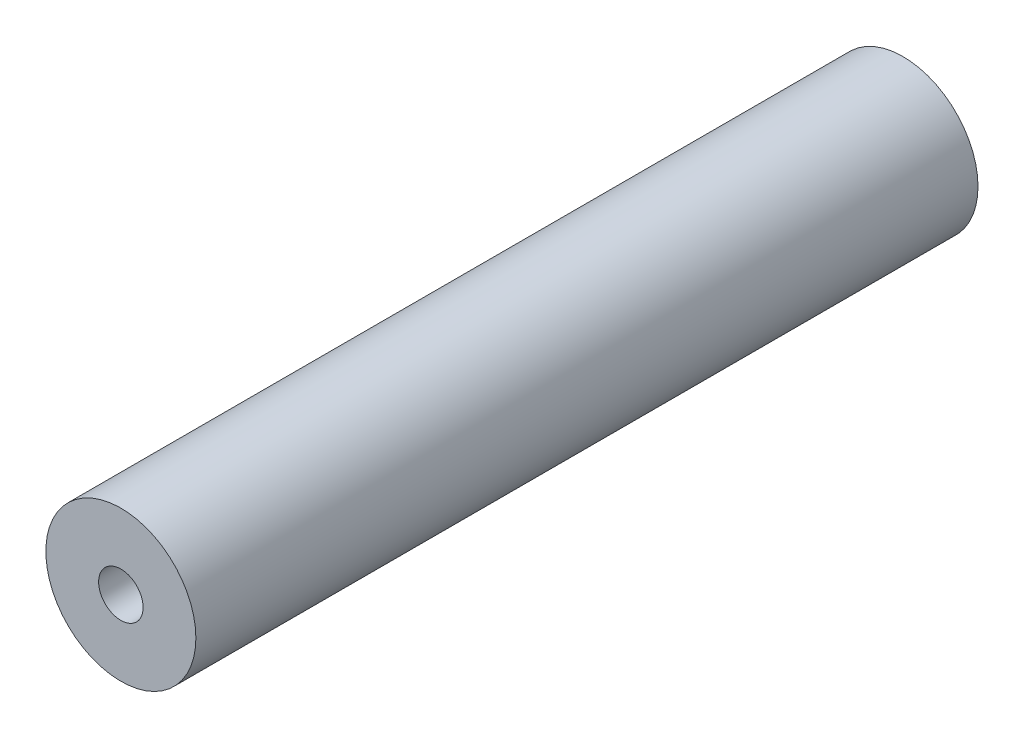
from build123d import *

# Parameters (mm, degrees)
SKETCH1_R                  = 6.4
BOSS_EXTRUDE1_DEPTH        = 66.73
F_10_24_TAPPED_HOLE1_D     = 3.7973
F_10_24_TAPPED_HOLE1_DEPTH = 12.83
F_10_24_TAPPED_HOLE1_TIP   = 1.140824014
F_10_24_TAPPED_HOLE2_D     = 3.7973
F_10_24_TAPPED_HOLE2_DEPTH = 12.83
F_10_24_TAPPED_HOLE2_TIP   = 1.140824014


with BuildPart() as part:
    # Sketch1 → Boss-Extrude1 (new body)
    with BuildSketch(Plane.XY):
        Circle(SKETCH1_R)
    extrude(amount=BOSS_EXTRUDE1_DEPTH)

    # #10-24 Tapped Hole1
    with Locations(Plane(origin=(0, 0, 0), x_dir=(-1, 0, 0), z_dir=(0, 0, -1))):
        with Locations((0, 0)):
            Hole(F_10_24_TAPPED_HOLE1_D / 2, depth=F_10_24_TAPPED_HOLE1_DEPTH)
            with Locations((0, 0, -(F_10_24_TAPPED_HOLE1_DEPTH + F_10_24_TAPPED_HOLE1_TIP / 2))):  # 118° drill point
                Cone(0, F_10_24_TAPPED_HOLE1_D / 2, F_10_24_TAPPED_HOLE1_TIP, mode=Mode.SUBTRACT)

    # #10-24 Tapped Hole2
    with Locations(Plane.XY.offset(66.73)):
        with Locations((0, 0)):
            Hole(F_10_24_TAPPED_HOLE2_D / 2, depth=F_10_24_TAPPED_HOLE2_DEPTH)
            with Locations((0, 0, -(F_10_24_TAPPED_HOLE2_DEPTH + F_10_24_TAPPED_HOLE2_TIP / 2))):  # 118° drill point
                Cone(0, F_10_24_TAPPED_HOLE2_D / 2, F_10_24_TAPPED_HOLE2_TIP, mode=Mode.SUBTRACT)


solid = part.part
